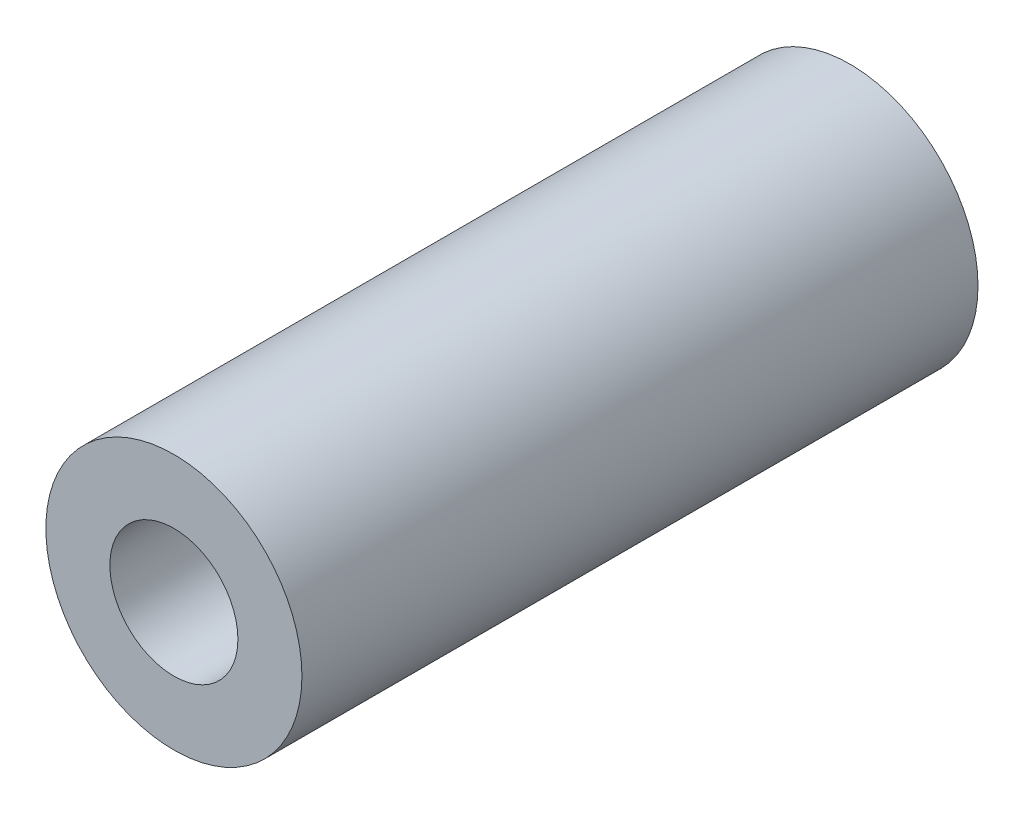
from build123d import *

# Parameters (mm, degrees)
SKETCH1_R                 = 5
BOSS_EXTRUDE1_DEPTH       = 26.4
F_5_0MM_DOWEL_HOLE1_D     = 5
F_5_0MM_DOWEL_HOLE1_DEPTH = 26.4


with BuildPart() as part:
    # Sketch1 → Boss-Extrude1 (new body)
    with BuildSketch(Plane.XY):
        Circle(SKETCH1_R)
    extrude(amount=BOSS_EXTRUDE1_DEPTH)

    # Ø5.0mm Dowel Hole1
    with Locations(Plane.XY.offset(26.4)):
        with Locations((0, 0)):
            Hole(F_5_0MM_DOWEL_HOLE1_D / 2, depth=F_5_0MM_DOWEL_HOLE1_DEPTH)


solid = part.part
